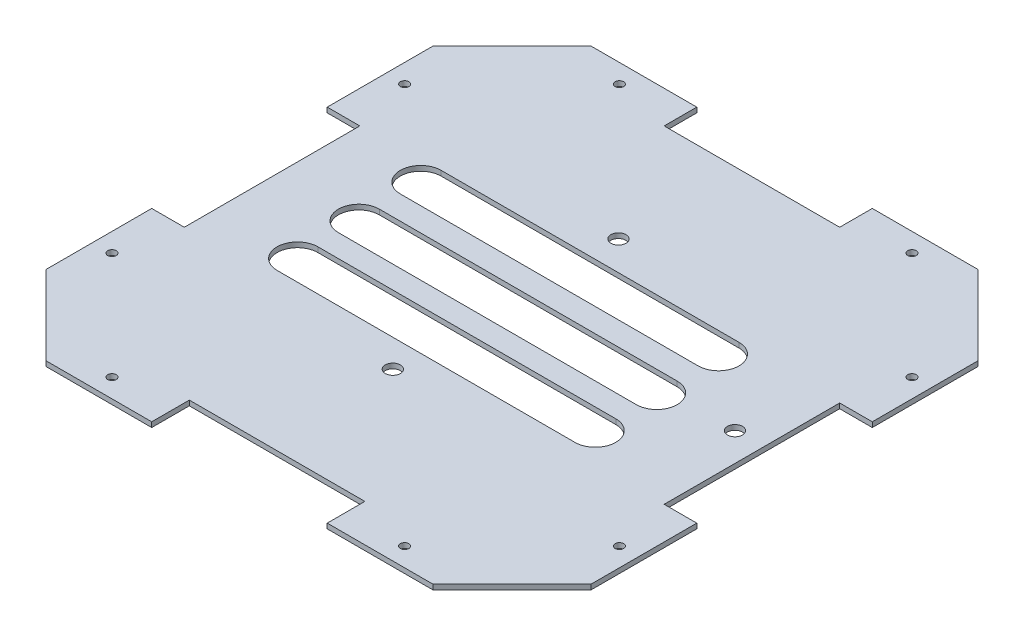
from build123d import *

# Parameters (mm, degrees)
SKETCH_1_R          = 1.7
EXTRUDE_1_DEPTH     = 2
SKETCH_3_R          = 3
CUT_EXTRUDE_1_DEPTH = 10
CUT_EXTRUDE_2_DEPTH = 10


with BuildPart() as part:
    # 草图1 → 凸台-拉伸1 (new body)
    with BuildSketch(Plane(origin=(0, 0, 0), x_dir=(1, 0, 0), z_dir=(0, 1, 0))):
        Polygon((0, -9.790421162), (0, 32.375054838), (13, 32.375054838), (13, 102.375054838), (0, 102.375054838), (0, 144.54053128), (31.526911935, 176.067443214), (73.692388376, 176.067443215), (73.692388376, 163.067443215), (143.692388376, 163.067443215), (143.692388376, 176.067443215), (185.857864376, 176.067443214), (217.384776311, 144.54053128), (217.384776311, 102.375054838), (204.384776311, 102.375054838), (204.384776311, 32.375054838), (217.384776311, 32.375054838), (217.384776311, -9.790421162), (185.857864376, -41.317333096), (143.692388376, -41.317333096), (143.692388376, -26.317333096), (73.692388376, -26.317333096), (73.692388376, -41.317333096), (31.526911935, -41.317333096), align=None)
        with Locations((209.884776311, 9.021225987)):
            Circle(SKETCH_1_R, mode=Mode.SUBTRACT)
        with Locations((209.884776311, 125.728884132)):
            Circle(SKETCH_1_R, mode=Mode.SUBTRACT)
        with Locations((167.046217228, 168.567443215)):
            Circle(SKETCH_1_R, mode=Mode.SUBTRACT)
        with Locations((50.338559083, 168.567443214)):
            Circle(SKETCH_1_R, mode=Mode.SUBTRACT)
        with Locations((7.5, 125.728884132)):
            Circle(SKETCH_1_R, mode=Mode.SUBTRACT)
        with Locations((7.5, 9.021225987)):
            Circle(SKETCH_1_R, mode=Mode.SUBTRACT)
        with Locations((50.338559083, -33.817333096)):
            Circle(SKETCH_1_R, mode=Mode.SUBTRACT)
        with Locations((167.046217228, -33.817333096)):
            Circle(SKETCH_1_R, mode=Mode.SUBTRACT)
    extrude(amount=EXTRUDE_1_DEPTH)

    # 草图3 → 切除-拉伸1 (cut)
    with BuildSketch(Plane(origin=(0, 2, 0), x_dir=(1, 0, 0), z_dir=(0, 1, 0))):
        with Locations((103.610094152, 114.918520178)):
            Circle(SKETCH_3_R)
        with Locations((103.610094152, 24.918520178)):
            Circle(SKETCH_3_R)
        with Locations((193.068894152, 71.918520178)):
            Circle(SKETCH_3_R)
    extrude(amount=-CUT_EXTRUDE_1_DEPTH, mode=Mode.SUBTRACT)

    # 草图4 → 切除-拉伸2 (cut)
    with BuildSketch(Plane(origin=(0, 2, 0), x_dir=(1, 0, 0), z_dir=(0, 1, 0))):
        with BuildLine():
            Line((44.561779376, 103.251399725), (163.361103837, 103.251399725))
            ThreePointArc((163.361103837, 103.251399725), (171.508845116, 95.103658445), (163.361103837, 86.955917166))
            Line((163.361103837, 86.955917166), (44.561779376, 86.955917166))
            ThreePointArc((44.561779376, 86.955917166), (36.414038096, 95.103658445), (44.561779376, 103.251399725))
        make_face()
        with BuildLine():
            Line((45.613100831, 77.534957336), (164.412425292, 77.534957336))
            ThreePointArc((164.412425292, 77.534957336), (172.560166571, 69.387216057), (164.412425292, 61.239474778))
            Line((164.412425292, 61.239474778), (45.613100831, 61.239474778))
            ThreePointArc((45.613100831, 61.239474778), (37.465359552, 69.387216057), (45.613100831, 77.534957336))
        make_face()
        with BuildLine():
            Line((46.401591922, 52.262309138), (165.200916384, 52.262309138))
            ThreePointArc((165.200916384, 52.262309138), (173.348657663, 44.114567858), (165.200916384, 35.966826579))
            Line((165.200916384, 35.966826579), (46.401591922, 35.966826579))
            ThreePointArc((46.401591922, 35.966826579), (38.253850643, 44.114567858), (46.401591922, 52.262309138))
        make_face()
    extrude(amount=-CUT_EXTRUDE_2_DEPTH, mode=Mode.SUBTRACT)


solid = part.part
